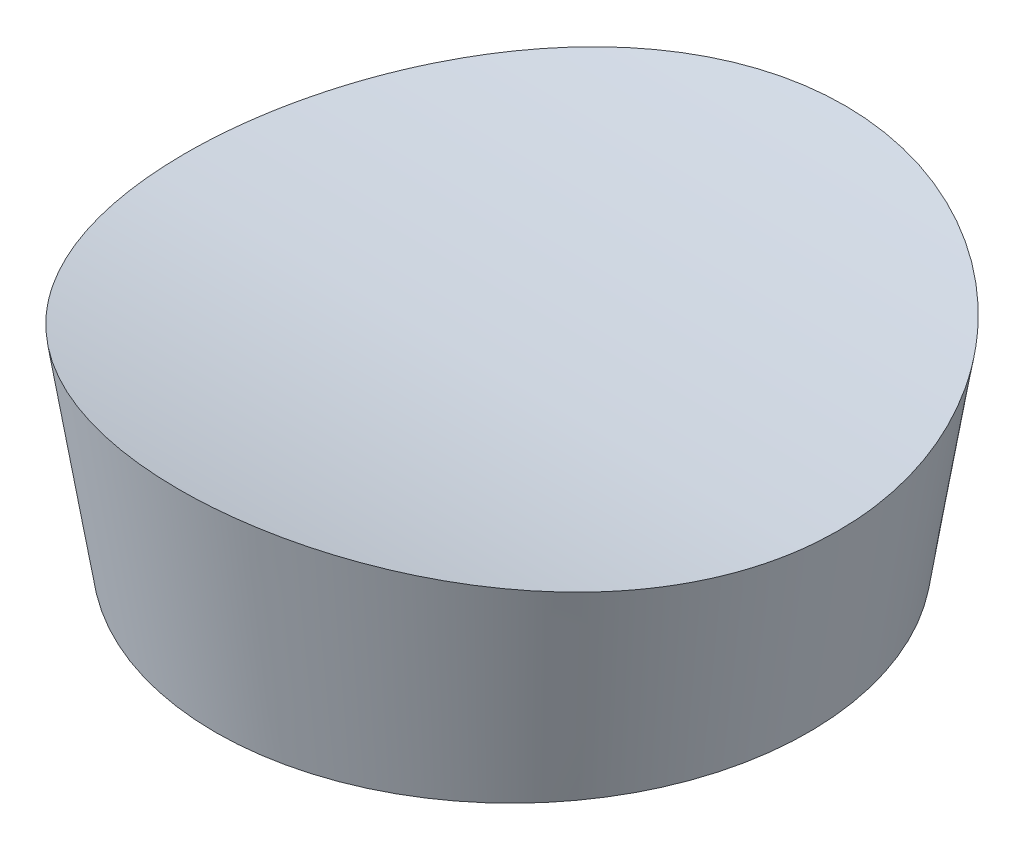
from build123d import *

# Parameters (mm, degrees)
SKETCH1_R               = 12.5
BOSS_EXTRUDE1_DEPTH     = 10
BOSS_EXTRUDE1_TAPER     = -9
SKETCH2_R               = 9.2
CUT_EXTRUDE1_DEPTH      = 2
SKETCH3_R               = 61.5
CUT_EXTRUDE2_DEPTH      = 15.083844503
CUT_EXTRUDE2_DEPTH_BACK = 15.083844503


with BuildPart() as part:
    # Sketch1 → Boss-Extrude1 (new body)
    with BuildSketch(Plane(origin=(0, 0, 0), x_dir=(1, 0, 0), z_dir=(0, 1, 0))):
        Circle(SKETCH1_R)
    extrude(amount=BOSS_EXTRUDE1_DEPTH, taper=BOSS_EXTRUDE1_TAPER)

    # Sketch2 → Cut-Extrude1 (cut)
    with BuildSketch(Plane.XZ):
        Circle(SKETCH2_R)
    extrude(amount=-CUT_EXTRUDE1_DEPTH, mode=Mode.SUBTRACT)

    # Sketch3 → Cut-Extrude2 (cut, two sides)
    with BuildSketch(Plane(origin=(0, 0, 0), x_dir=(0, 0, -1), z_dir=(1, 0, 0))) as cut_extrude2_sk:
        with Locations((0, 69.5)):
            Circle(SKETCH3_R)
    extrude(amount=CUT_EXTRUDE2_DEPTH, mode=Mode.SUBTRACT)
    extrude(cut_extrude2_sk.sketch, amount=-CUT_EXTRUDE2_DEPTH_BACK, mode=Mode.SUBTRACT)


solid = part.part
